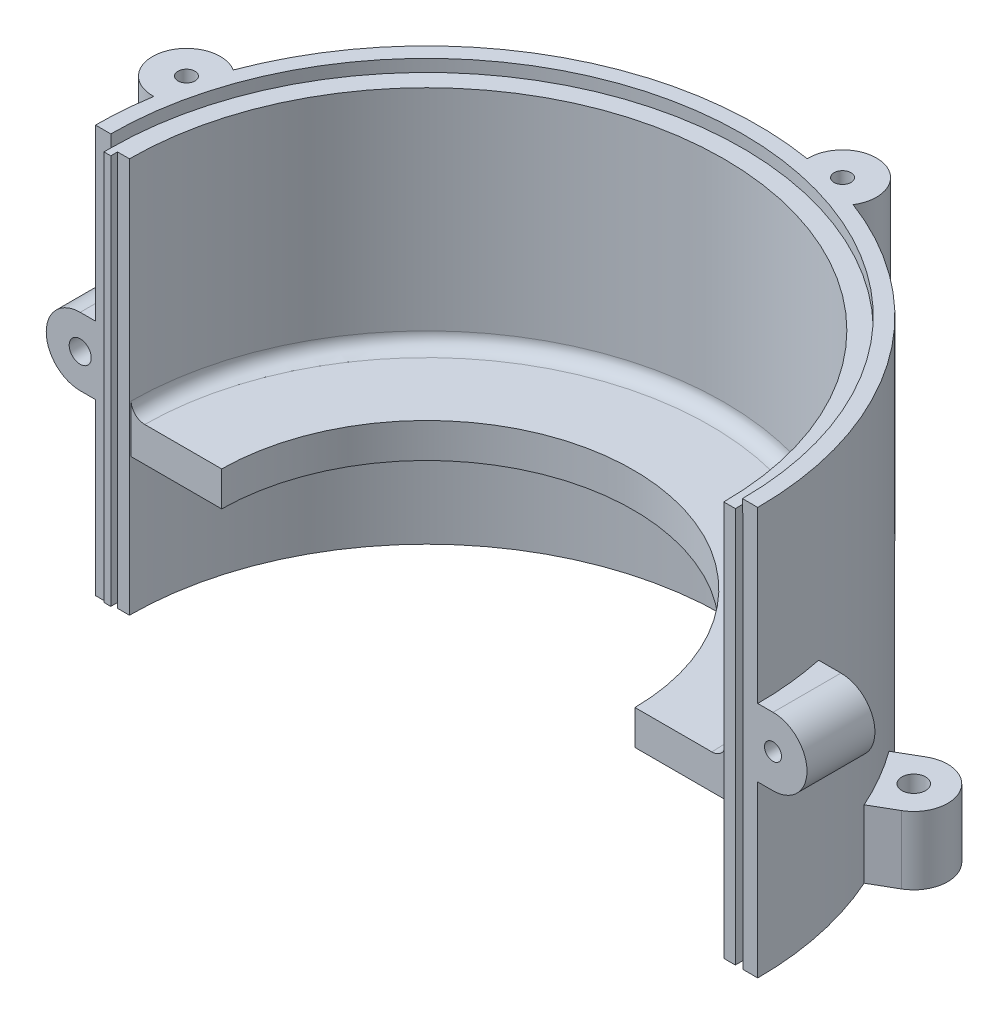
from build123d import *

# Parameters (mm, degrees)
REVOLU_O2_ANGLE            = 180
ESBO_O4_R                  = 10
RESSALTO_EXTRUS_O1_DEPTH   = 35
RESSALTO_EXTRUS_O2_DEPTH   = 20
ESBO_O8_R                  = 3.5
CORTE_EXTRUS_O2_DEPTH      = 20
PADR_OCIRCULAR1_COUNT      = 6
ESBO_O6_R                  = 2.5
CORTE_EXTRUS_O1_DEPTH      = 15
ESBO_O10_W                 = 2.2
ESBO_O10_H                 = 116.4
CORTE_EXTRUS_O4_DEPTH      = 3.5
ESBO_O11_W                 = 2
ESBO_O11_H                 = 114.9
RESSALTO_EXTRUS_O5_DEPTH   = 2
ESBO_O12_R                 = 3.25
RESSALTO_EXTRUS_O6_DEPTH   = 20
ESBO_O13_R                 = 2.5
RESSALTO_EXTRUS_O7_DEPTH   = 20
ESBO_O16_R                 = 93
CORTE_EXTRUS_O6_DEPTH      = 10
ESBO_O17_R                 = 92.967356783
ESBO_O17_R_2               = 90.967356783
CORTE_EXTRUS_O7_DEPTH      = 1.5
CORTE_EXTRUS_O9_DEPTH      = 41.2
CORTE_EXTRUS_O9_DEPTH_BACK = 80.8


with BuildPart() as part:
    # Esboço3 → Revolução2 (revolve)
    with BuildSketch(Plane.XY):
        with BuildLine():
            Line((97.5, 79.8), (97.5, 11.304491341))
            Line((97.5, 11.304491341), (97.5, 0))
            Line((97.5, 0), (97.5, -40.2))
            Line((97.5, -40.2), (87.5, -40.2))
            Line((87.5, -40.2), (87.5, 0))
            Line((87.5, 0), (60.342408243, 0))
            Line((60.342408243, 0), (60.342408243, 10.2))
            Line((60.342408243, 10.2), (83.5, 10.2))
            ThreePointArc((83.5, 10.2), (86.328427125, 11.371572875), (87.5, 14.2))
            Line((87.5, 14.2), (87.5, 76.2))
            Line((87.5, 76.2), (93, 76.2))
            Line((93, 76.2), (93, 79.8))
            Line((93, 79.8), (97.5, 79.8))
        make_face()
    revolve(axis=Axis((0, -3.322055656, 0), (0, 1, 0)), revolution_arc=REVOLU_O2_ANGLE)

    # Esboço4 → Ressalto-extrusão1 (add)
    with BuildSketch(Plane(origin=(0, 79.8, 0), x_dir=(1, 0, 0), z_dir=(0, 1, 0))):
        with Locations((25.881656302, 96.591656302)):
            Circle(ESBO_O4_R)
        with Locations((-96.591656302, 25.881656302)):
            Circle(ESBO_O4_R)
    extrude(amount=-RESSALTO_EXTRUS_O1_DEPTH)

    # Esboço5 → Ressalto-extrusão2 (add)
    with BuildSketch(Plane.XZ.offset(40.2)):
        with BuildLine():
            Line((10, -105), (10, -96.985823706))
            Line((10, -96.985823706), (-10, -96.985823706))
            Line((-10, -96.985823706), (-10, -105))
            ThreePointArc((-10, -105), (0, -115), (10, -105))
        make_face()
    ressalto_extrus_o2 = extrude(amount=-RESSALTO_EXTRUS_O2_DEPTH)

    # Esboço8 → Corte-extrusão2 (cut)
    with BuildSketch(Plane.XZ.offset(40.2)):
        with Locations((0, -105)):
            Circle(ESBO_O8_R)
    corte_extrus_o2 = extrude(amount=-CORTE_EXTRUS_O2_DEPTH, mode=Mode.SUBTRACT)

    # PadrãoCircular1: Ressalto-extrusão2, Corte-extrusão2 ×6 about axis, 3 skipped
    padr_ocircular1_axis = Axis((0, 0, 0), (0, 1, 0))
    add([ressalto_extrus_o2.rotate(padr_ocircular1_axis, i * 360 / PADR_OCIRCULAR1_COUNT) for i in range(1, PADR_OCIRCULAR1_COUNT) if i not in (2, 3, 4)])
    add([corte_extrus_o2.rotate(padr_ocircular1_axis, i * 360 / PADR_OCIRCULAR1_COUNT) for i in range(1, PADR_OCIRCULAR1_COUNT) if i not in (2, 3, 4)], mode=Mode.SUBTRACT)

    # Esboço6 → Corte-extrusão1 (cut)
    with BuildSketch(Plane(origin=(0, 79.8, 0), x_dir=(1, 0, 0), z_dir=(0, 1, 0))):
        with Locations((25.881656302, 96.591656302)):
            Circle(ESBO_O6_R)
        with Locations((-96.591656302, 25.881656302)):
            Circle(ESBO_O6_R)
    extrude(amount=-CORTE_EXTRUS_O1_DEPTH, mode=Mode.SUBTRACT)

    # Esboço10 → Corte-extrusão4 (cut)
    with BuildSketch(Plane.XY):
        with Locations((92, 18)):
            Rectangle(ESBO_O10_W, ESBO_O10_H)
    extrude(amount=-CORTE_EXTRUS_O4_DEPTH, mode=Mode.SUBTRACT)

    # Esboço11 → Ressalto-extrusão5 (add)
    with BuildSketch(Plane.XY):
        with Locations((-92, 18.75)):
            Rectangle(ESBO_O11_W, ESBO_O11_H)
    extrude(amount=RESSALTO_EXTRUS_O5_DEPTH)

    # Esboço12 → Ressalto-extrusão6 (add)
    with BuildSketch(Plane.XY):
        with BuildLine():
            Line((-102, 29.8), (-87.5, 29.8))
            Line((-87.5, 29.8), (-87.5, 9.8))
            Line((-87.5, 9.8), (-102, 9.8))
            ThreePointArc((-102, 9.8), (-112, 19.8), (-102, 29.8))
        make_face()
        with Locations((-102, 19.8)):
            Circle(ESBO_O12_R, mode=Mode.SUBTRACT)
    extrude(amount=-RESSALTO_EXTRUS_O6_DEPTH)

    # Esboço13 → Ressalto-extrusão7 (add)
    with BuildSketch(Plane.XY):
        with BuildLine():
            Line((102, 29.8), (93.1, 29.8))
            Line((93.1, 29.8), (93.1, 9.8))
            Line((93.1, 9.8), (102, 9.8))
            ThreePointArc((102, 9.8), (112, 19.8), (102, 29.8))
        make_face()
        with Locations((102, 19.8)):
            Circle(ESBO_O13_R, mode=Mode.SUBTRACT)
    extrude(amount=-RESSALTO_EXTRUS_O7_DEPTH)

    # Esboço16 → Corte-extrusão6 (cut)
    with BuildSketch(Plane(origin=(0, 76.2, 0), x_dir=(1, 0, 0), z_dir=(0, 1, 0))):
        Circle(ESBO_O16_R)
    extrude(amount=CORTE_EXTRUS_O6_DEPTH, mode=Mode.SUBTRACT)

    # Esboço17 → Corte-extrusão7 (cut)
    with BuildSketch(Plane.XZ.offset(40.2)):
        Circle(ESBO_O17_R)
        Circle(ESBO_O17_R_2, mode=Mode.SUBTRACT)
    extrude(amount=-CORTE_EXTRUS_O7_DEPTH, mode=Mode.SUBTRACT)

    # Esboço21 → Corte-extrusão9 (cut, two sides)
    with BuildSketch(Plane.XZ) as corte_extrus_o9_sk:
        with BuildLine():
            Line((-87.5, 0), (87.5, 0))
            ThreePointArc((87.5, 0), (87.499642853, -0.25000102), (87.498571417, -0.5))
            Line((87.498571417, -0.5), (60.84035372, -0.5))
            ThreePointArc((60.84035372, -0.5), (0, -60.842408243), (-60.84035372, -0.5))
            Line((-60.84035372, -0.5), (-87.498571417, -0.5))
            ThreePointArc((-87.498571417, -0.5), (-87.499642853, -0.25000102), (-87.5, 0))
        make_face()
    extrude(amount=CORTE_EXTRUS_O9_DEPTH, mode=Mode.SUBTRACT)
    extrude(corte_extrus_o9_sk.sketch, amount=-CORTE_EXTRUS_O9_DEPTH_BACK, mode=Mode.SUBTRACT)


solid = part.part
